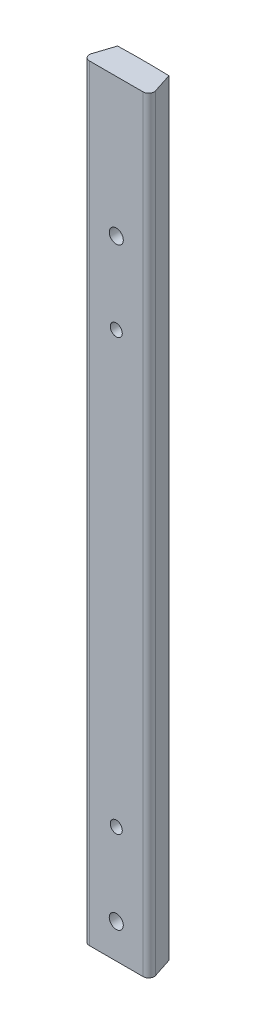
from build123d import *

# Parameters (mm, degrees)
BOSS_EXTRUDE1_DEPTH                                 = 178
CBORE_FOR_4_BINDING_HEAD_MACHINE_SCREW3_D           = 3.2639
CBORE_FOR_4_BINDING_HEAD_MACHINE_SCREW3_CBORE_D     = 6.74624
CBORE_FOR_4_BINDING_HEAD_MACHINE_SCREW3_CBORE_DEPTH = 1.7272
SKETCH3_R                                           = 1.397
CUT_EXTRUDE1_DEPTH                                  = 7.35
FILLET1_R                                           = 1.27


with BuildPart() as part:
    # Sketch2 → Boss-Extrude1 (new body)
    with BuildSketch(Plane(origin=(0, 0, 0), x_dir=(1, 0, 0), z_dir=(0, 1, 0))):
        with BuildLine():
            Line((8.001, -203.2), (-8.001, -203.2))
            Line((-8.001, -203.2), (-5.969, -196.937688608))
            ThreePointArc((-5.969, -196.937688608), (0, -196.85), (5.969, -196.937688608))
            Line((5.969, -196.937688608), (8.001, -203.2))
        make_face()
    extrude(amount=BOSS_EXTRUDE1_DEPTH)

    # CBORE for #4 Binding Head Machine Screw3 (through all)
    with Locations(Plane(origin=(0, 8, 196.85), x_dir=(-1, 0, 0), z_dir=(0, 0, -1))):
        with Locations((0, 0), (0, 137.875371205)):
            CounterBoreHole(CBORE_FOR_4_BINDING_HEAD_MACHINE_SCREW3_D / 2, CBORE_FOR_4_BINDING_HEAD_MACHINE_SCREW3_CBORE_D / 2, CBORE_FOR_4_BINDING_HEAD_MACHINE_SCREW3_CBORE_DEPTH)

    # Sketch3 → Cut-Extrude1 (cut, through all)
    with BuildSketch(Plane.XY.offset(196.85)):
        with Locations((0, 27)):
            Circle(SKETCH3_R)
        with Locations((0, 127)):
            Circle(SKETCH3_R)
    extrude(amount=CUT_EXTRUDE1_DEPTH, mode=Mode.SUBTRACT)

    # Fillet1
    fillet1_edges = [part.edges().sort_by_distance(p)[0] for p in [
        (8.001, 89, 203.2),
        (-8.001, 89, 203.2),
    ]]
    fillet(fillet1_edges, radius=FILLET1_R)


solid = part.part
